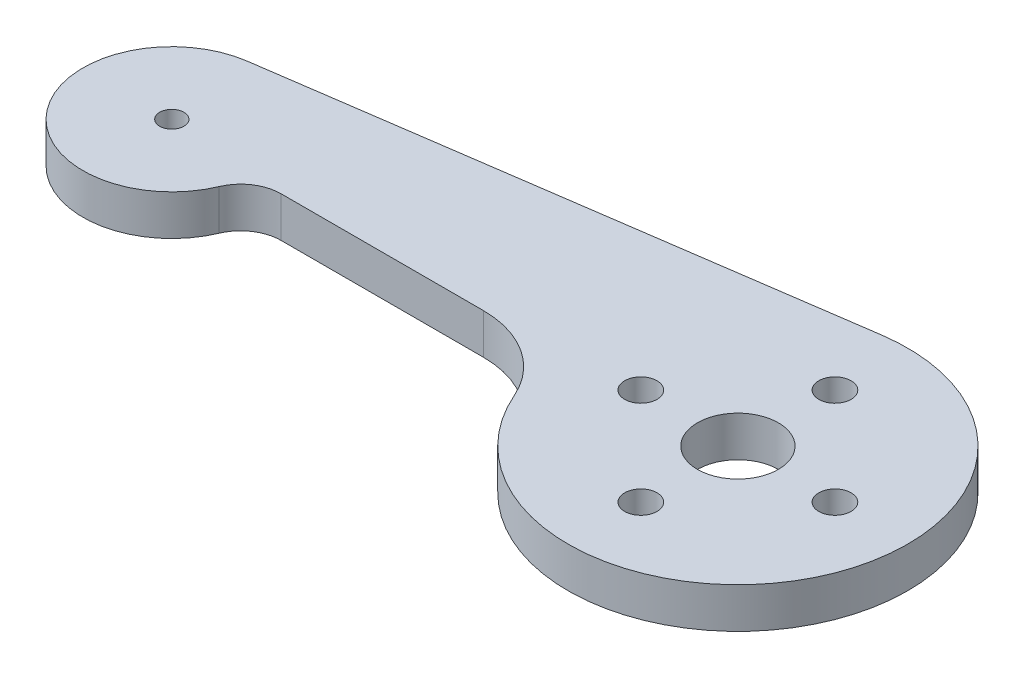
from build123d import *

# Parameters (mm, degrees)
SKETCH1_R           = 1.5
SKETCH1_R_2         = 5
SKETCH1_R_3         = 2
BOSS_EXTRUDE1_DEPTH = 5


with BuildPart() as part:
    # Sketch1 → Boss-Extrude1 (new body)
    with BuildSketch(Plane(origin=(0, 0, 0), x_dir=(1, 0, 0), z_dir=(0, 1, 0))):
        with BuildLine():
            Line((-1.571428571, 10.887176505), (67, 20.784609691))
            ThreePointArc((67, 20.784609691), (88.351830916, -10.208344725), (50.75875, -8.412746189))
            ThreePointArc((50.75875, -8.412746189), (46.333095385, -3.17793327), (39.76375, -1.220029725))
            Line((39.76375, -1.220029725), (14.741479919, -1.220029725))
            ThreePointArc((14.741479919, -1.220029725), (11.977316072, -2.05356861), (10.134767445, -4.276270436))
            ThreePointArc((10.134767445, -4.276270436), (-8.707193804, -6.721962218), (-1.571428571, 10.887176505))
        make_face()
        Circle(SKETCH1_R, mode=Mode.SUBTRACT)
        with Locations((70, 0)):
            Circle(SKETCH1_R_2, mode=Mode.SUBTRACT)
        with Locations((70, 12)):
            Circle(SKETCH1_R_3, mode=Mode.SUBTRACT)
        with Locations((82, 0)):
            Circle(SKETCH1_R_3, mode=Mode.SUBTRACT)
        with Locations((70, -12)):
            Circle(SKETCH1_R_3, mode=Mode.SUBTRACT)
        with Locations((58, 0)):
            Circle(SKETCH1_R_3, mode=Mode.SUBTRACT)
    extrude(amount=BOSS_EXTRUDE1_DEPTH)


solid = part.part
